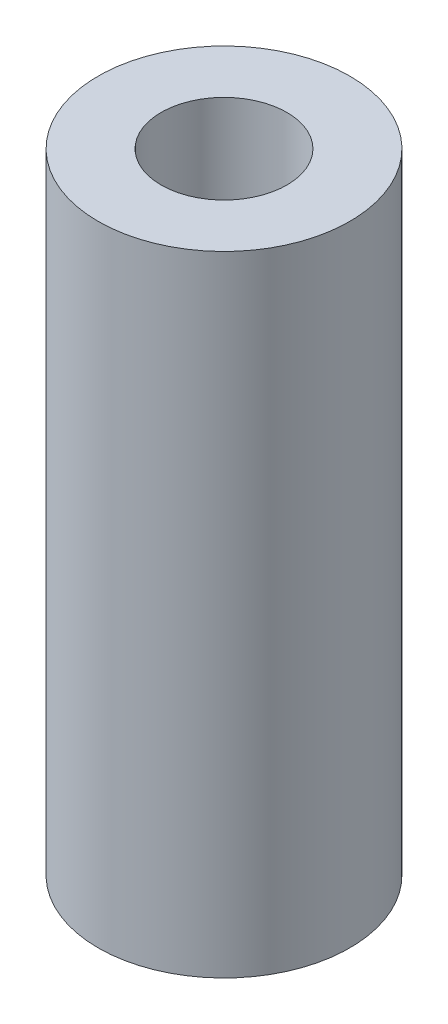
from build123d import *

# Parameters (mm, degrees)
SKIZZE1_R                       = 5
SKIZZE1_R_2                     = 2.5
AUFSATZ_LINEAR_AUSTRAGEN1_DEPTH = 25


with BuildPart() as part:
    # Skizze1 → Aufsatz-Linear austragen1 (new body)
    with BuildSketch(Plane(origin=(0, 0, 0), x_dir=(1, 0, 0), z_dir=(0, 1, 0))):
        Circle(SKIZZE1_R)
        Circle(SKIZZE1_R_2, mode=Mode.SUBTRACT)
    extrude(amount=AUFSATZ_LINEAR_AUSTRAGEN1_DEPTH)


solid = part.part
